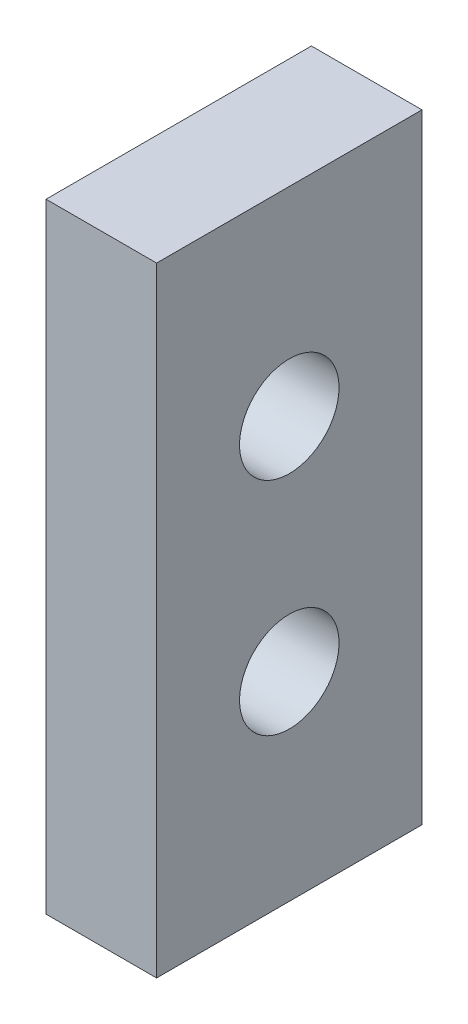
from build123d import *

# Parameters (mm, degrees)
SKETCH1_W           = 12
SKETCH1_H           = 28
SKETCH1_R           = 2.25
BOSS_EXTRUDE1_DEPTH = 5


with BuildPart() as part:
    # Sketch1 → Boss-Extrude1 (new body)
    with BuildSketch(Plane(origin=(0, 0, 0), x_dir=(0, 0, -1), z_dir=(1, 0, 0))):
        Rectangle(SKETCH1_W, SKETCH1_H)
        with Locations((0, 5)):
            Circle(SKETCH1_R, mode=Mode.SUBTRACT)
        with Locations((0, -5)):
            Circle(SKETCH1_R, mode=Mode.SUBTRACT)
    extrude(amount=BOSS_EXTRUDE1_DEPTH)


solid = part.part
